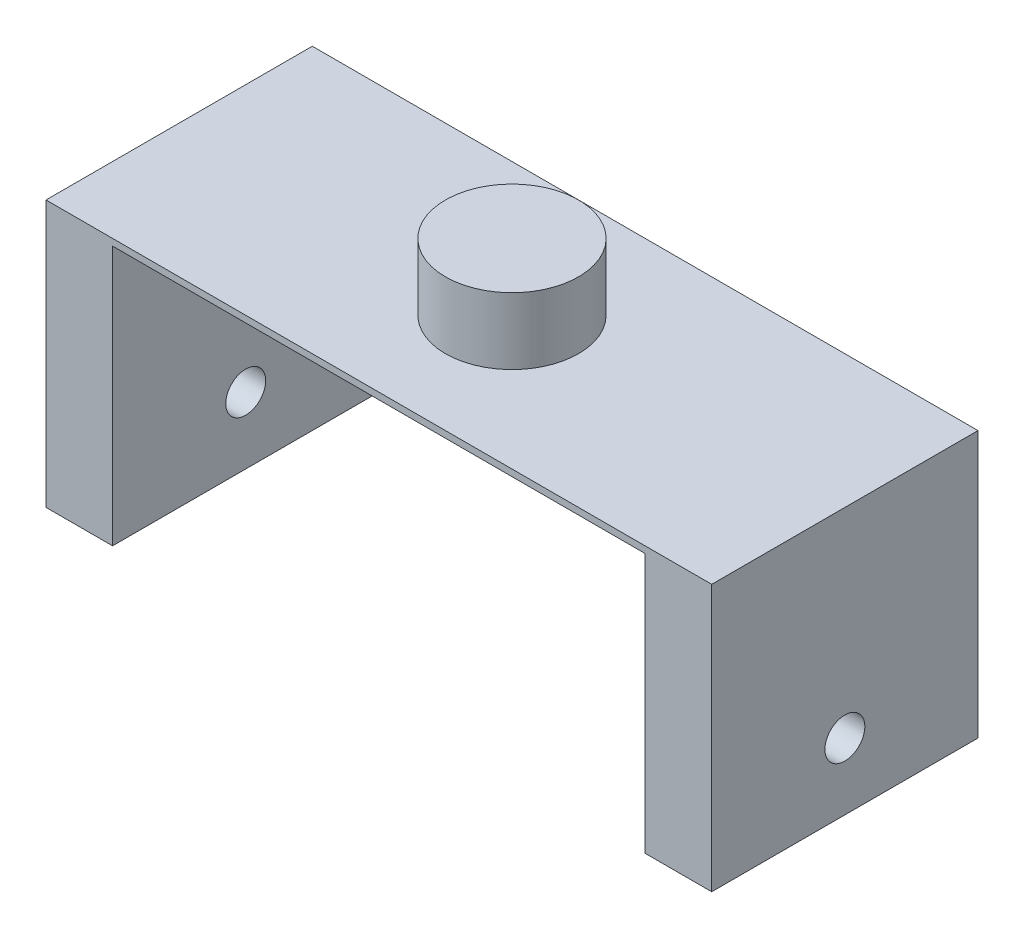
from build123d import *

# Parameters (mm, degrees)
SKETCH1_W           = 25.4
SKETCH1_H           = 10.16
BOSS_EXTRUDE2_DEPTH = 0.254
SKETCH2_R           = 2.54
BOSS_EXTRUDE3_DEPTH = 2.54
SKETCH3_W           = 2.54
SKETCH3_H           = 10.16
BOSS_EXTRUDE4_DEPTH = 10.16
SKETCH4_R           = 0.762
CUT_EXTRUDE2_DEPTH  = 25.4


with BuildPart() as part:
    # Sketch1 → Boss-Extrude2 (new body)
    with BuildSketch(Plane(origin=(0, 0, 0), x_dir=(1, 0, 0), z_dir=(0, 1, 0))):
        with Locations((12.7, -5.08)):
            Rectangle(SKETCH1_W, SKETCH1_H)
    extrude(amount=BOSS_EXTRUDE2_DEPTH)

    # Sketch2 → Boss-Extrude3 (add)
    with BuildSketch(Plane(origin=(0, 0.254, 0), x_dir=(1, 0, 0), z_dir=(0, 1, 0))):
        with Locations((12.7, -5.08)):
            Circle(SKETCH2_R)
    extrude(amount=BOSS_EXTRUDE3_DEPTH)

    # Sketch3 → Boss-Extrude4 (add)
    with BuildSketch(Plane(origin=(0, 0.254, 0), x_dir=(1, 0, 0), z_dir=(0, 1, 0))):
        with Locations((1.27, -5.08)):
            Rectangle(SKETCH3_W, SKETCH3_H)
        with Locations((24.13, -5.08)):
            Rectangle(SKETCH3_W, SKETCH3_H)
    extrude(amount=-BOSS_EXTRUDE4_DEPTH)

    # Sketch4 → Cut-Extrude2 (cut)
    with BuildSketch(Plane.ZY):
        with Locations((5.08, -7.366)):
            Circle(SKETCH4_R)
    extrude(amount=-CUT_EXTRUDE2_DEPTH, mode=Mode.SUBTRACT)


solid = part.part
